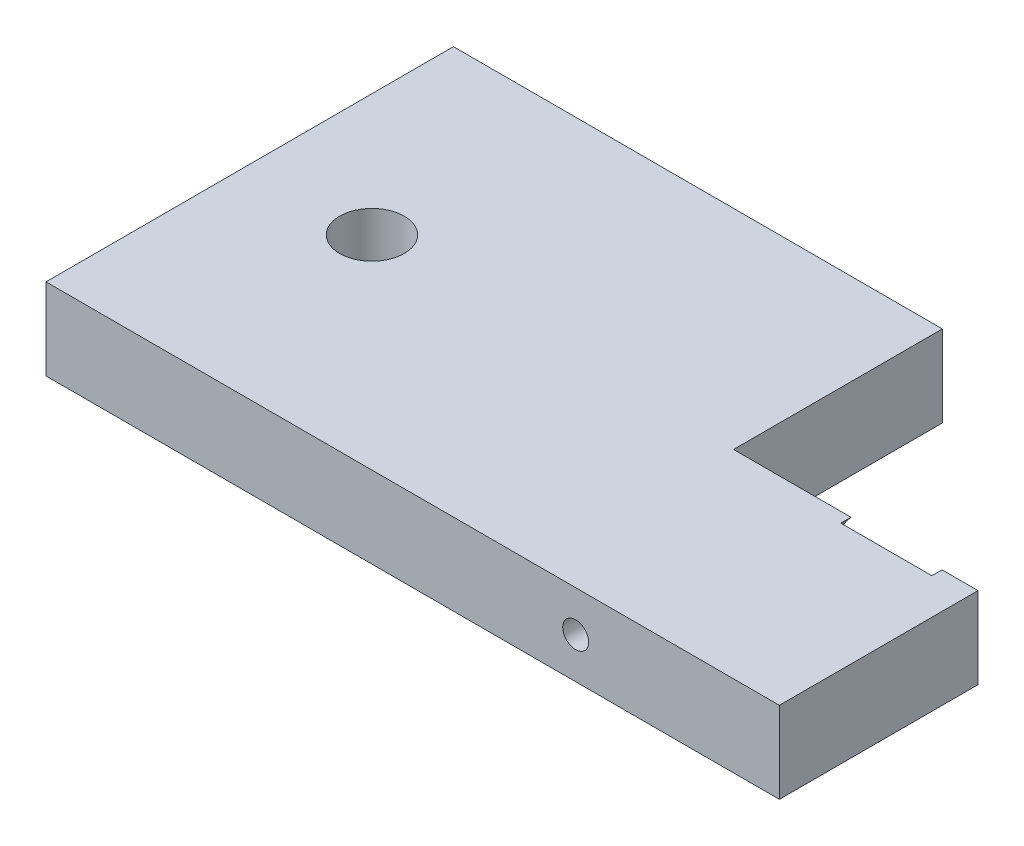
from build123d import *

# Parameters (mm, degrees)
BOSS_EXTRUDE1_DEPTH     = 12.7
F_10_32_TAPPED_HOLE1_D  = 4.0386
F_3_8_CLEARANCE_HOLE1_D = 10.0838
SKETCH9_R               = 9.525
CUT_EXTRUDE1_DEPTH      = 1.5875


with BuildPart() as part:
    # Sketch1 → Boss-Extrude1 (new body)
    with BuildSketch(Plane(origin=(0, 0, 0), x_dir=(1, 0, 0), z_dir=(0, 1, 0))):
        Polygon((-114.3, 31.75), (-114.3, -0.79375), (-76.2, -0.79375), (-76.2, -31.75), (-190.5, -31.75), (-190.5, 31.75), align=None)
    extrude(amount=BOSS_EXTRUDE1_DEPTH)

    # #10-32 Tapped Hole1 (through all)
    with Locations(Plane(origin=(0, 0, 0.79375), x_dir=(-1, 0, 0), z_dir=(0, 0, -1))):
        with Locations((107.95, 6.35)):
            Hole(F_10_32_TAPPED_HOLE1_D / 2)

    # 3/8 Clearance Hole1 (through all)
    with Locations(Plane(origin=(0, 12.7, 0), x_dir=(1, 0, 0), z_dir=(0, 1, 0))):
        with Locations((-171.45, 0)):
            Hole(F_3_8_CLEARANCE_HOLE1_D / 2)

    # Sketch9 → Cut-Extrude1 (cut)
    with BuildSketch(Plane(origin=(0, 0, 0.79375), x_dir=(-1, 0, 0), z_dir=(0, 0, -1))):
        with Locations((88.9, 6.35)):
            Circle(SKETCH9_R)
    extrude(amount=-CUT_EXTRUDE1_DEPTH, mode=Mode.SUBTRACT)


solid = part.part
